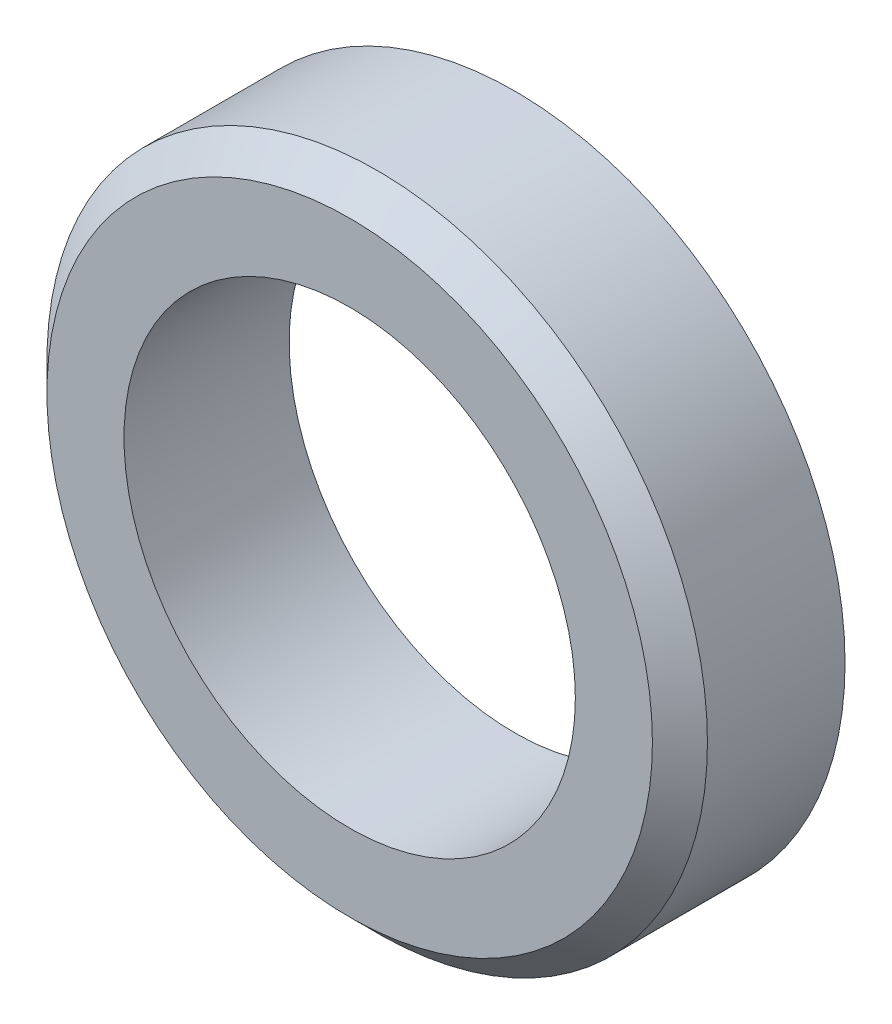
from build123d import *

# Parameters (mm, degrees)
ESQUISSE1_R             = 6
BOSS_EXTRU_1_DEPTH      = 3
ESQUISSE2_R             = 4.1
ENL_V_MAT_EXTRU_1_DEPTH = 4
CHANFREIN1_SIZE         = 0.5


with BuildPart() as part:
    # Esquisse1 → Boss.-Extru.1 (new body)
    with BuildSketch(Plane.XY):
        Circle(ESQUISSE1_R)
    extrude(amount=BOSS_EXTRU_1_DEPTH)

    # Esquisse2 → Enlèv. mat.-Extru.1 (cut, through all)
    with BuildSketch(Plane.XY.offset(3)):
        Circle(ESQUISSE2_R)
    extrude(amount=-ENL_V_MAT_EXTRU_1_DEPTH, mode=Mode.SUBTRACT)

    # Chanfrein1
    chanfrein1_edges = [part.edges().sort_by_distance(p)[0] for p in [
        (-6, 0, 3),
    ]]
    chamfer(chanfrein1_edges, length=CHANFREIN1_SIZE)


solid = part.part
